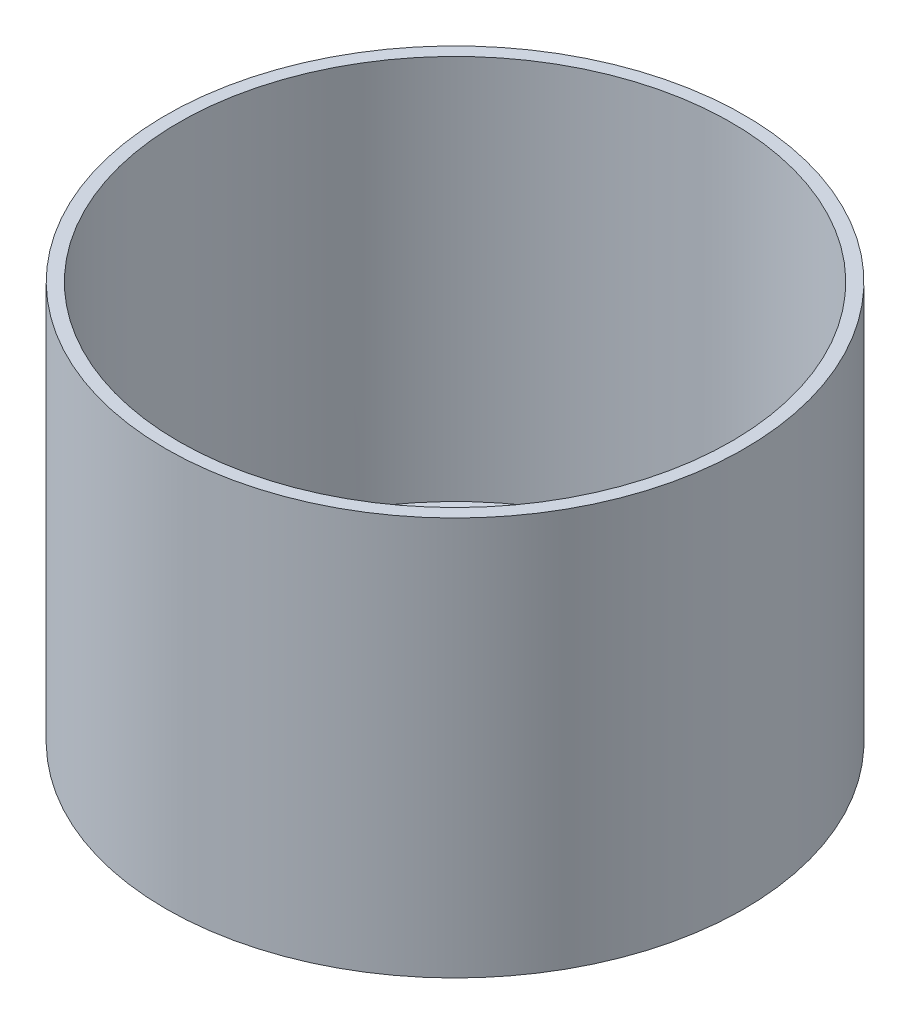
from build123d import *

# Parameters (mm, degrees)
SKETCH1_R           = 45
BOSS_EXTRUDE1_DEPTH = 2
SKETCH2_R           = 45
SKETCH2_R_2         = 43
BOSS_EXTRUDE2_DEPTH = 60
BOSS_EXTRUDE3_DEPTH = 20


with BuildPart() as part:
    # Sketch1 → Boss-Extrude1 (new body)
    with BuildSketch(Plane(origin=(0, 0, 0), x_dir=(1, 0, 0), z_dir=(0, 1, 0))):
        with Locations((16.5, 24.5)):
            Circle(SKETCH1_R)
    extrude(amount=BOSS_EXTRUDE1_DEPTH)

    # Sketch2 → Boss-Extrude2 (add)
    with BuildSketch(Plane(origin=(0, 2, 0), x_dir=(1, 0, 0), z_dir=(0, 1, 0))):
        with Locations((16.5, 24.5)):
            Circle(SKETCH2_R)
        with Locations((16.5, 24.5)):
            Circle(SKETCH2_R_2, mode=Mode.SUBTRACT)
    extrude(amount=BOSS_EXTRUDE2_DEPTH)

    # Sketch4 → Boss-Extrude3 (add)
    with BuildSketch(Plane(origin=(0, 2, 0), x_dir=(1, 0, 0), z_dir=(0, 1, 0))):
        with BuildLine():
            Line((16.62283723, -5.732814302), (13.748295666, -4.763073196))
            ThreePointArc((13.748295666, -4.763073196), (-7.263767503, 12.607148038), (-2.774667592, -14.282987074))
            Line((-2.774667592, -14.282987074), (13.119042931, -19.644810544))
            ThreePointArc((13.119042931, -19.644810544), (22.396673207, -14.58419971), (16.62283723, -5.732814302))
        make_face()
        with BuildLine():
            Line((13.692970384, -17.943554089), (-2.348778298, -12.531789198))
            ThreePointArc((-2.348778298, -12.531789198), (-5.619876263, 11.444627158), (11.352459564, -5.803805808))
            Line((11.352459564, -5.803805808), (16.469142545, -7.529944639))
            ThreePointArc((16.469142545, -7.529944639), (20.636876468, -14.217879696), (13.692970384, -17.943554089))
        make_face(mode=Mode.SUBTRACT)
    extrude(amount=BOSS_EXTRUDE3_DEPTH)


solid = part.part
